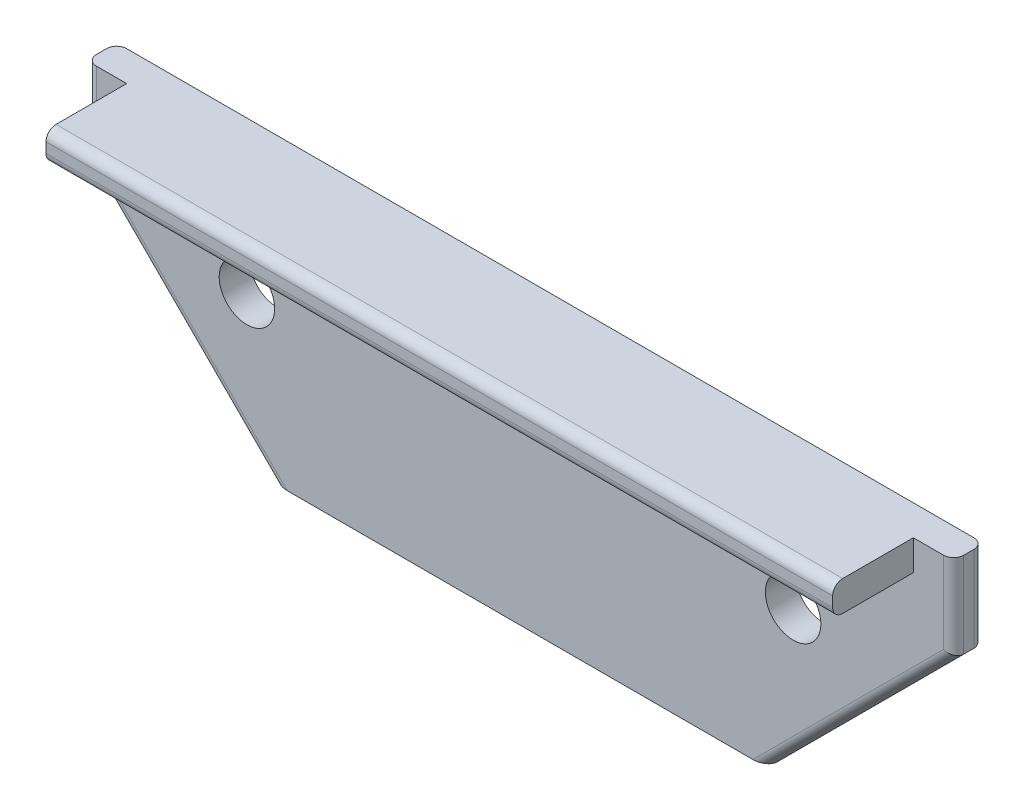
from build123d import *

# Parameters (mm, degrees)
BOSS_EXTRUDE1_DEPTH       = 9.525
SKETCH2_W                 = 247.649999748
SKETCH2_H                 = 9.52499999
BOSS_EXTRUDE2_DEPTH       = 25.4
M16_CLEARANCE_HOLE1_D     = 17.462499982
M16_CLEARANCE_HOLE1_DEPTH = 34.925
FILLET1_R                 = 3.175


with BuildPart() as part:
    # Sketch1 → Boss-Extrude1 (new body)
    with BuildSketch(Plane.XY.offset(-7.9375)):
        Polygon((136.524999861, 15.874999984), (136.524999861, 42.862499956), (-136.524999861, 42.862499956), (-136.524999861, 15.874999984), (-77.787499921, -42.862499956), (77.787499921, -42.862499956), align=None)
    extrude(amount=-BOSS_EXTRUDE1_DEPTH)

    # Sketch2 → Boss-Extrude2 (add)
    with BuildSketch(Plane.XY.offset(-7.9375)):
        with Locations((0, 38.099999961)):
            Rectangle(SKETCH2_W, SKETCH2_H)
    extrude(amount=BOSS_EXTRUDE2_DEPTH)

    # M16 Clearance Hole1
    with Locations(Plane(origin=(0, 0, -17.4625), x_dir=(-1, 0, 0), z_dir=(0, 0, -1))):
        with Locations((-85.978999912, 4.762499995), (85.978999912, 4.762499995)):
            Hole(M16_CLEARANCE_HOLE1_D / 2, depth=M16_CLEARANCE_HOLE1_DEPTH)

    # Fillet1
    fillet1_edges = [part.edges().sort_by_distance(p)[0] for p in [
        (-136.524999861, 29.36874997, -17.4625),
        (-107.156249891, -13.493749986, -17.4625),
        (0, 33.337499966, 17.4625),
        (0, 42.862499956, 17.4625),
        (107.156249891, -13.493749986, -17.4625),
        (-107.156249891, -13.493749986, -7.9375),
        (-136.524999861, 29.36874997, -7.9375),
        (136.524999861, 29.36874997, -17.4625),
        (136.524999861, 29.36874997, -7.9375),
        (107.156249891, -13.493749986, -7.9375),
    ]]
    fillet(fillet1_edges, radius=FILLET1_R)


solid = part.part
